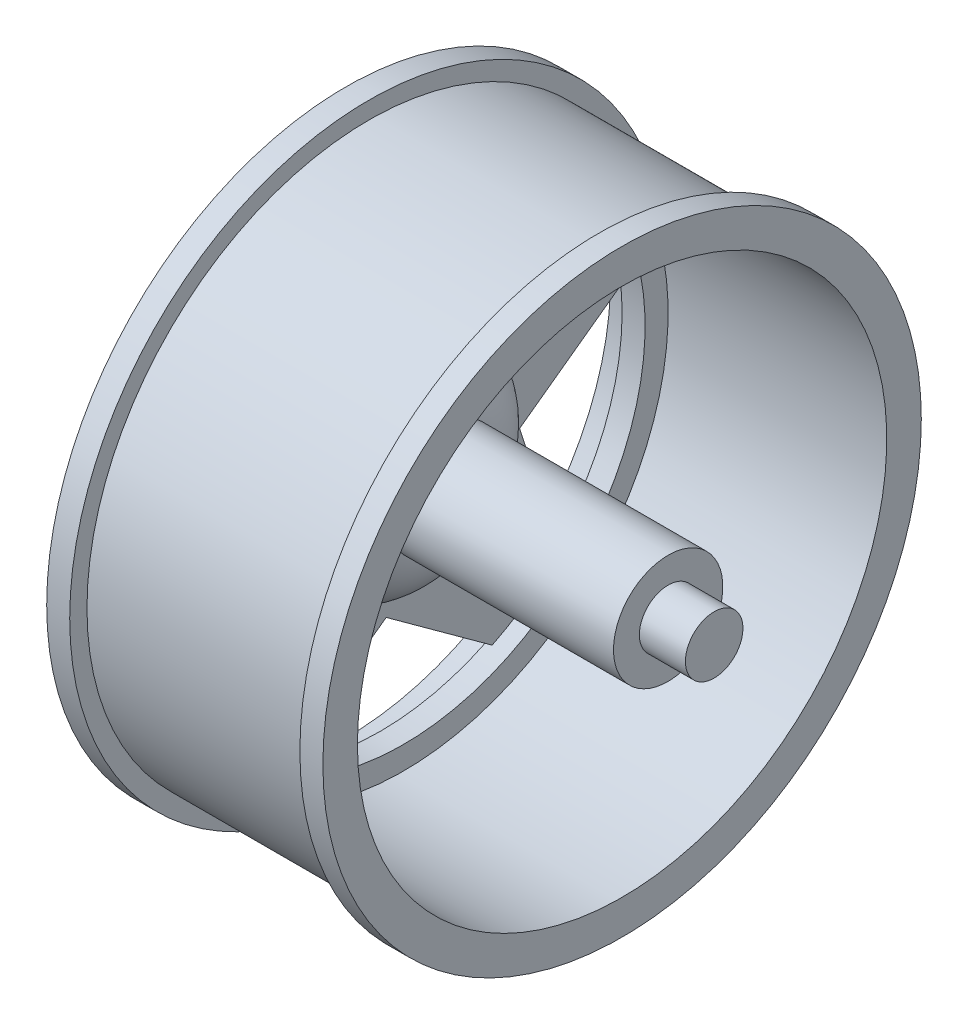
from build123d import *

# Parameters (mm, degrees)
RESSALTO_EXTRUS_O1_DEPTH = 2


with BuildPart() as part:
    # Esboço1 → Revolução1 (revolve)
    with BuildSketch(Plane.XY):
        Polygon((0, 26), (0, 23), (3, 23), (3, 21), (5, 21), (5, 23), (24, 23), (24, 26), (22, 26), (22, 24.5), (2, 24.5), (2, 26), align=None)
    revolve(axis=Axis((0, 0, 0), (1, 0, 0)))

    # Esboço2 → Ressalto-extrusão1 (add)
    with BuildSketch(Plane(origin=(1.5, 0, 0), x_dir=(0, 0, -1), z_dir=(1, 0, 0))):
        with BuildLine():
            Line((2.953388355, 22.80959222), (7.161813683, 9.857390871))
            Line((7.161813683, 9.857390871), (20.780564122, 9.857390871))
            ThreePointArc((20.780564122, 9.857390871), (21.874299875, 7.107390871), (22.605858507, 4.239712391))
            Line((22.605858507, 4.239712391), (11.58805796, -3.765188272))
            Line((11.58805796, -3.765188272), (15.796483288, -16.717389621))
            ThreePointArc((15.796483288, -16.717389621), (13.519060803, -18.607390871), (11.017800547, -20.18930586))
            Line((11.017800547, -20.18930586), (0, -12.184405197))
            Line((0, -12.184405197), (-11.017800547, -20.18930586))
            ThreePointArc((-11.017800547, -20.18930586), (-13.519060803, -18.607390871), (-15.796483288, -16.717389621))
            Line((-15.796483288, -16.717389621), (-11.58805796, -3.765188272))
            Line((-11.58805796, -3.765188272), (-22.605858507, 4.239712391))
            ThreePointArc((-22.605858507, 4.239712391), (-21.874299875, 7.107390871), (-20.780564122, 9.857390871))
            Line((-20.780564122, 9.857390871), (-7.161813683, 9.857390871))
            Line((-7.161813683, 9.857390871), (-2.953388355, 22.80959222))
            ThreePointArc((-2.953388355, 22.80959222), (0, 23), (2.953388355, 22.80959222))
        make_face()
    extrude(amount=RESSALTO_EXTRUS_O1_DEPTH)


with BuildPart() as body_2:
    # Esboço4 → Revolução2 (revolve)
    with BuildSketch(Plane.XY):
        with BuildLine():
            Line((28, 4.75), (8.5, 4.75))
            ThreePointArc((8.5, 4.75), (6.48630468, 8.502205348), (2.5, 10))
            Line((2.5, 10), (2.5, 0))
            Line((2.5, 0), (32, 0))
            Line((32, 0), (32, 2.5))
            Line((32, 2.5), (28, 2.5))
            Line((28, 2.5), (28, 4.75))
        make_face()
    revolve(axis=Axis((35.369555181, 0, 0), (1, 0, 0)))


with BuildPart() as corte_revolu_o1_tool:
    # Esboço3 → Corte-Revolução1 (revolve)
    with BuildSketch(Plane.XY):
        with BuildLine():
            Line((1.5, 21.212369611), (1.5, 23))
            Line((1.5, 23), (3, 23))
            ThreePointArc((3, 23), (1.924677874, 22.379162481), (1.5, 21.212369611))
        make_face()
        with BuildLine():
            Line((4.5, 4.75), (4.5, 0))
            Line((4.5, 0), (1.5, 0))
            Line((1.5, 0), (1.5, 9))
            ThreePointArc((1.5, 9), (4.205980501, 8.461747013), (6.5, 6.928932188))
            Line((6.5, 6.928932188), (6.5, 4.75))
            Line((6.5, 4.75), (4.5, 4.75))
        make_face()
    revolve(axis=Axis((0, 0, 0), (-1, 0, 0)))


with BuildPart() as part_1:
    add(part.part)

    # Corte-Revolução1: cut by corte_revolu_o1_tool
    add(corte_revolu_o1_tool.part, mode=Mode.SUBTRACT)


with BuildPart() as body_2_1:
    add(body_2.part)

    # Corte-Revolução1: cut by corte_revolu_o1_tool
    add(corte_revolu_o1_tool.part, mode=Mode.SUBTRACT)


solid = Compound([part_1.part, body_2_1.part])
